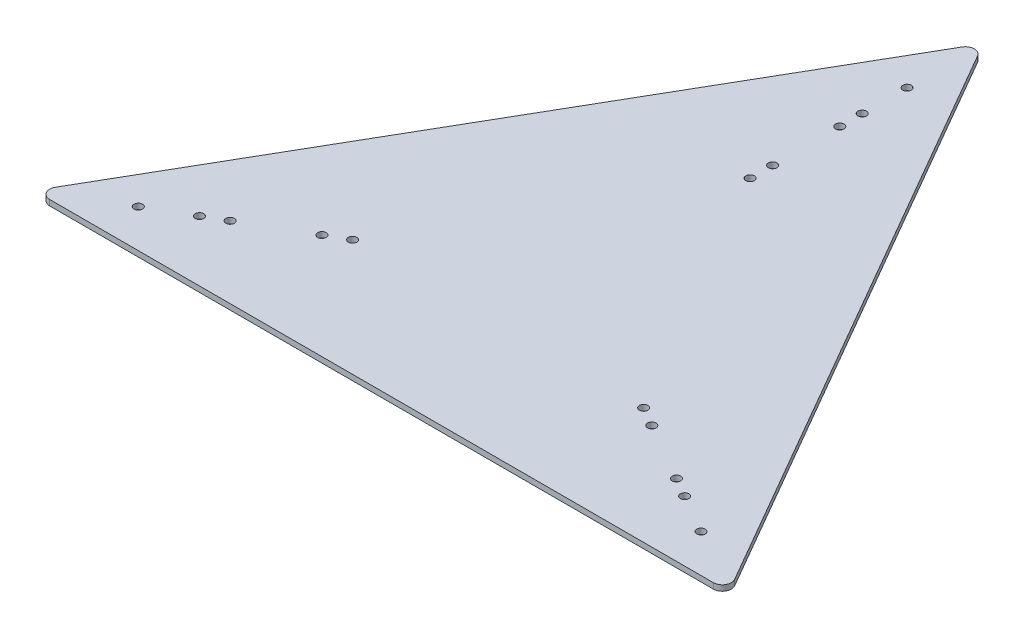
from build123d import *

# Parameters (mm, degrees)
BOSS_EXTRUDE1_DEPTH = 3.175
FILLET1_R           = 5.08
SKETCH2_R           = 2.413
CUT_EXTRUDE1_DEPTH  = 14.153467


with BuildPart() as part:
    # Sketch1 → Boss-Extrude1 (new body)
    with BuildSketch(Plane(origin=(0, 0, 0), x_dir=(1, 0, 0), z_dir=(0, 1, 0))):
        Polygon((0, 0), (393.7, 0), (196.85, 340.95420147), align=None)
    extrude(amount=BOSS_EXTRUDE1_DEPTH)

    # Fillet1
    fillet1_edges = [part.edges().sort_by_distance(p)[0] for p in [
        (196.85, 1.5875, -340.95420147),
        (393.7, 1.5875, 0),
        (0, 1.5875, 0),
    ]]
    fillet(fillet1_edges, radius=FILLET1_R)

    # Sketch2 → Cut-Extrude1 (cut)
    with BuildSketch(Plane(origin=(0, 3.175, 0), x_dir=(1, 0, 0), z_dir=(0, 1, 0))):
        with Locations((37.394976935, 21.59)):
            Circle(SKETCH2_R)
        with Locations((59.392022192, 34.29)):
            Circle(SKETCH2_R)
        with Locations((70.39054482, 40.64)):
            Circle(SKETCH2_R)
        with Locations((114.384635332, 66.04)):
            Circle(SKETCH2_R)
        with Locations((103.386112704, 59.69)):
            Circle(SKETCH2_R)
        with Locations((196.85, 297.77420147)):
            Circle(SKETCH2_R)
        with Locations((196.85, 272.37420147)):
            Circle(SKETCH2_R)
        with Locations((196.85, 259.67420147)):
            Circle(SKETCH2_R)
        with Locations((196.85, 221.57420147)):
            Circle(SKETCH2_R)
        with Locations((196.85, 208.87420147)):
            Circle(SKETCH2_R)
        with Locations((279.315364668, 66.04)):
            Circle(SKETCH2_R)
        with Locations((290.313887296, 59.69)):
            Circle(SKETCH2_R)
        with Locations((323.30945518, 40.64)):
            Circle(SKETCH2_R)
        with Locations((334.307977808, 34.29)):
            Circle(SKETCH2_R)
        with Locations((356.305023065, 21.59)):
            Circle(SKETCH2_R)
    extrude(amount=-CUT_EXTRUDE1_DEPTH, mode=Mode.SUBTRACT)


solid = part.part
